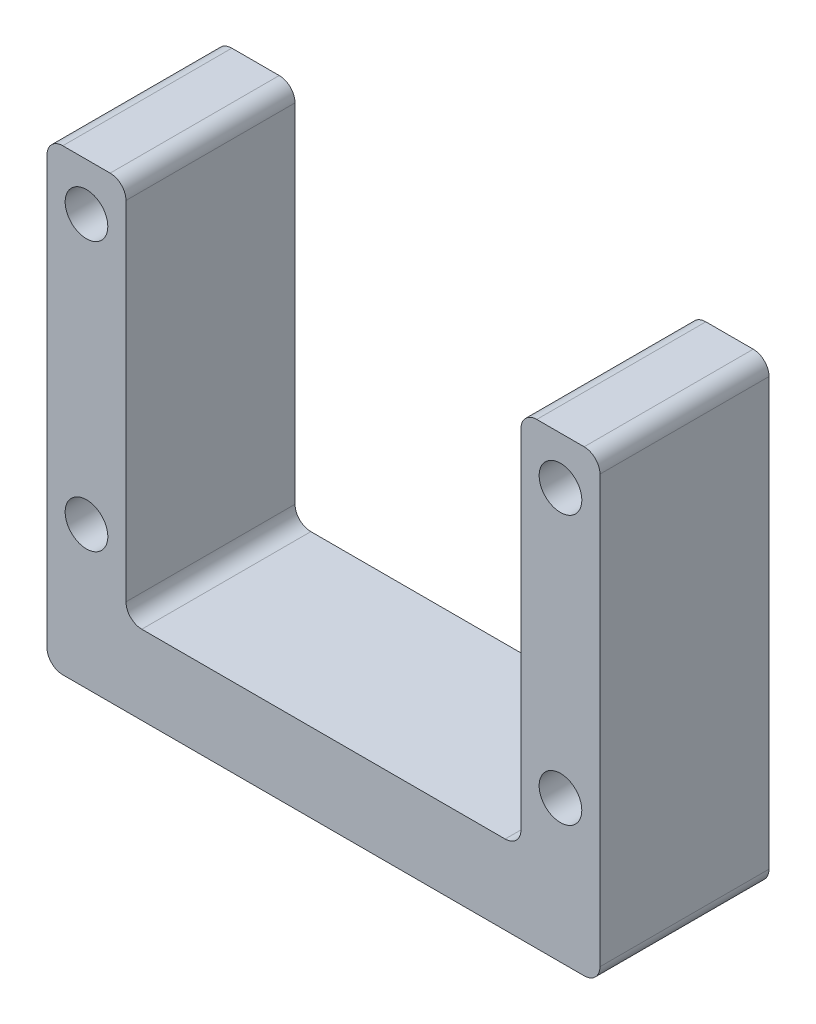
from build123d import *

# Parameters (mm, degrees)
BOSS_EXTRU_1_DEPTH           = 10.7
ESQUISSE2_R                  = 1.35
ENL_V_MAT_EXTRU_1_DEPTH      = 1
ENL_V_MAT_EXTRU_1_DEPTH_BACK = 11.7
CONG_1_R                     = 1


with BuildPart() as part:
    # Esquisse1 → Boss.-Extru.1 (new body)
    with BuildSketch(Plane.XY):
        Polygon((-12.5, 0), (12.5, 0), (12.5, 24), (17.5, 24), (17.5, -5), (-17.5, -5), (-17.5, 24), (-12.5, 24), align=None)
    extrude(amount=BOSS_EXTRU_1_DEPTH)

    # Esquisse2 → Enlèv. mat.-Extru.1 (cut, two sides)
    with BuildSketch(Plane.XY.offset(10.7)) as enl_v_mat_extru_1_sk:
        with Locations((-15, 21)):
            Circle(ESQUISSE2_R)
        with Locations((-15, 4)):
            Circle(ESQUISSE2_R)
        with Locations((15, 4)):
            Circle(ESQUISSE2_R)
        with Locations((15, 21)):
            Circle(ESQUISSE2_R)
    extrude(amount=ENL_V_MAT_EXTRU_1_DEPTH, mode=Mode.SUBTRACT)
    extrude(enl_v_mat_extru_1_sk.sketch, amount=-ENL_V_MAT_EXTRU_1_DEPTH_BACK, mode=Mode.SUBTRACT)

    # Congé1
    cong_1_edges = [part.edges().sort_by_distance(p)[0] for p in [
        (12.5, 24, 5.35),
        (17.5, 24, 5.35),
        (17.5, -5, 5.35),
        (-17.5, -5, 5.35),
        (-17.5, 24, 5.35),
        (-12.5, 24, 5.35),
        (-12.5, 0, 5.35),
        (12.5, 0, 5.35),
    ]]
    fillet(cong_1_edges, radius=CONG_1_R)


solid = part.part
